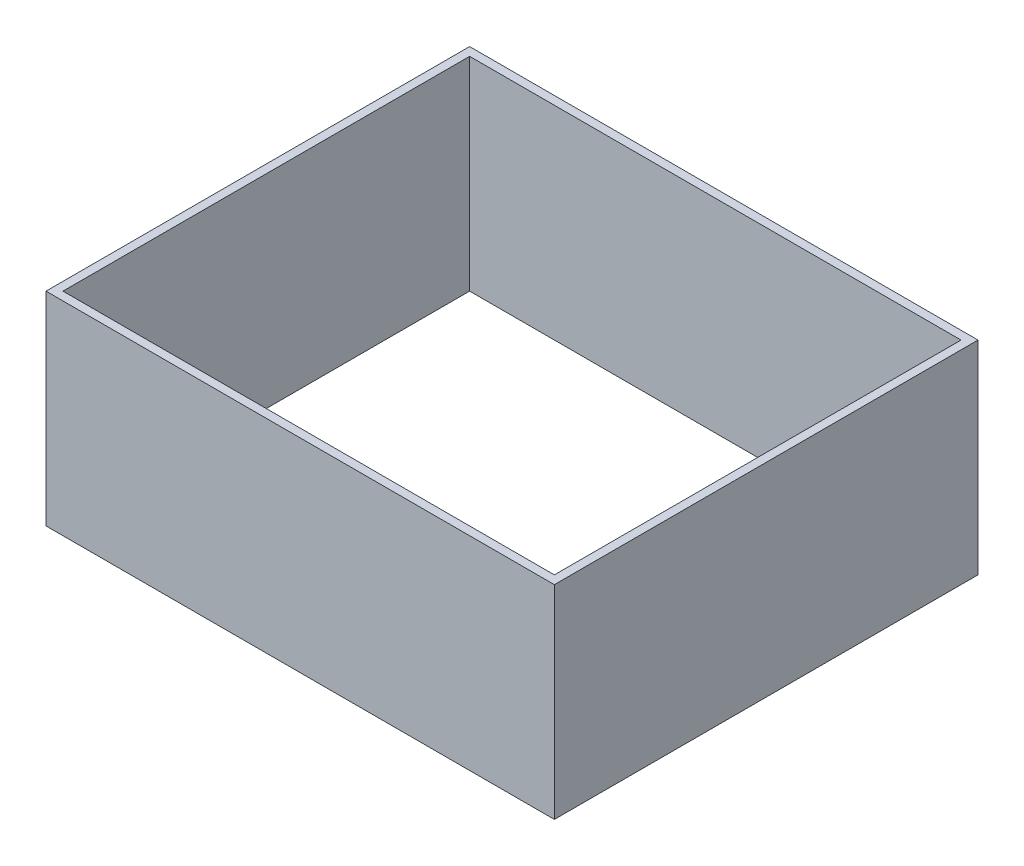
from build123d import *

# Parameters (mm, degrees)
SKETCH1_W           = 150
SKETCH1_H           = 125
BOSS_EXTRUDE1_DEPTH = 60
SHELL1_T            = -2.5


with BuildPart() as part:
    # Sketch1 → Boss-Extrude1 (new body)
    with BuildSketch(Plane(origin=(0, 0, 0), x_dir=(1, 0, 0), z_dir=(0, 1, 0))):
        Rectangle(SKETCH1_W, SKETCH1_H)
    extrude(amount=BOSS_EXTRUDE1_DEPTH)

    # Shell1
    shell1_openings = [part.faces().sort_by_distance(p)[0] for p in [
        (0, 60, 0),
        (0, 0, 0),
    ]]
    offset(amount=SHELL1_T, openings=shell1_openings, kind=Kind.INTERSECTION)


solid = part.part
